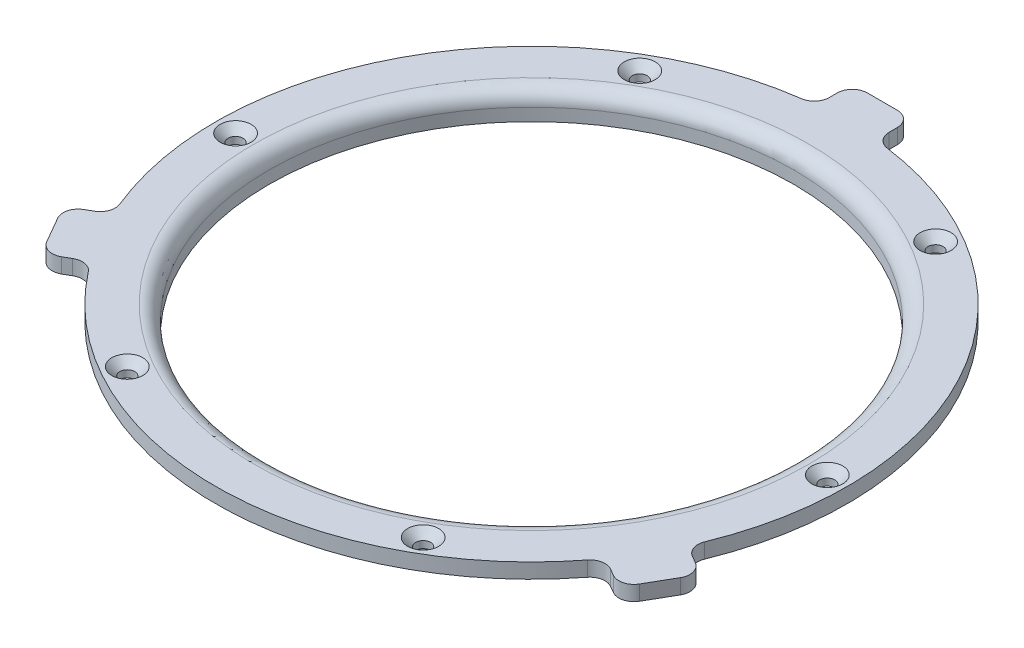
from build123d import *

# Parameters (mm, degrees)
CIRPATTERN1_COUNT        = 6
FILLET1_R                = 3
BOSS_EXTRUDE1_START      = 14.8
BOSS_EXTRUDE1_DEPTH      = 3
FILLET2_R                = 3
CIRPATTERN2_COUNT        = 3
FILLET2_OF_CIRPATTERN2_R = 3


with BuildPart() as part:
    # Sketch3 → Cap (revolve)
    with BuildSketch(Plane.XY):
        Polygon((-55, 9.3), (-52.5, 9.3), (-52.5, 14.8), (-63.2, 14.8), (-63.2, 11.8), (-55, 11.8), align=None)
    revolve(axis=Axis((0, 0, 0), (0, 1, 0)))

    # Sketch12 → CSK for M3 Flat Head Machine Screw1 (revolve, cut)
    with BuildSketch(Plane(origin=(-59.2, 14.8, 0), x_dir=(0, 0, 1), z_dir=(1, 0, 0))):
        Polygon((0, 0), (0, 9.791291), (1.5, 8.89), (1.5, 1.6), (3.1, 0), align=None)
    csk_for_m3_flat_head_machine_screw1 = revolve(axis=Axis((-59.2, 21.15, 0), (0, -1, 0)), mode=Mode.SUBTRACT)

    # CirPattern1: CSK for M3 Flat Head Machine Screw1 ×6 about axis
    cirpattern1_axis = Axis((0, 0, 0), (0, 1, 0))
    for i in range(1, CIRPATTERN1_COUNT):
        add(csk_for_m3_flat_head_machine_screw1.rotate(cirpattern1_axis, i * 360 / CIRPATTERN1_COUNT), mode=Mode.SUBTRACT)

    # Fillet1
    fillet1_edges = [part.edges().sort_by_distance(p)[0] for p in [
        (52.5, 14.8, 0),
    ]]
    fillet(fillet1_edges, radius=FILLET1_R)

    # Sketch14 → Boss-Extrude1 (add)
    with BuildSketch(Plane(origin=(0, 0, 0), x_dir=(1, 0, 0), z_dir=(0, 1, 0)).offset(BOSS_EXTRUDE1_START)):
        Polygon((-63.794983, -29.903848), (-57.794983, -40.296152), (-51.485594, -36.653425), (-57.485594, -26.26112), align=None)
    boss_extrude1 = extrude(amount=-BOSS_EXTRUDE1_DEPTH)

    # Fillet2
    fillet2_edges = [part.edges().sort_by_distance(p)[0] for p in [
        (-57.794983, 13.3, 40.296152),
        (-63.794983, 13.3, 29.903848),
        (-57.485594, 13.3, 26.26112),
        (-51.485594, 13.3, 36.653425),
    ]]
    fillet(fillet2_edges, radius=FILLET2_R)

    # CirPattern2: Boss-Extrude1 ×3 about axis
    cirpattern2_axis = Axis((0, 0, 0), (0, 1, 0))
    for i in range(1, CIRPATTERN2_COUNT):
        add(boss_extrude1.rotate(cirpattern2_axis, i * 360 / CIRPATTERN2_COUNT))

    # Fillet2 of CirPattern2
    fillet2_of_cirpattern2_edges = [part.edges().sort_by_distance(p)[0] for p in [
        (63.794983, 13.3, 29.903848),
        (57.794983, 13.3, 40.296152),
        (51.485594, 13.3, 36.653425),
        (57.485594, 13.3, 26.26112),
        (-6, 13.3, -70.2),
        (6, 13.3, -70.2),
        (6, 13.3, -62.914545),
        (-6, 13.3, -62.914545),
    ]]
    fillet(fillet2_of_cirpattern2_edges, radius=FILLET2_OF_CIRPATTERN2_R)


solid = part.part
